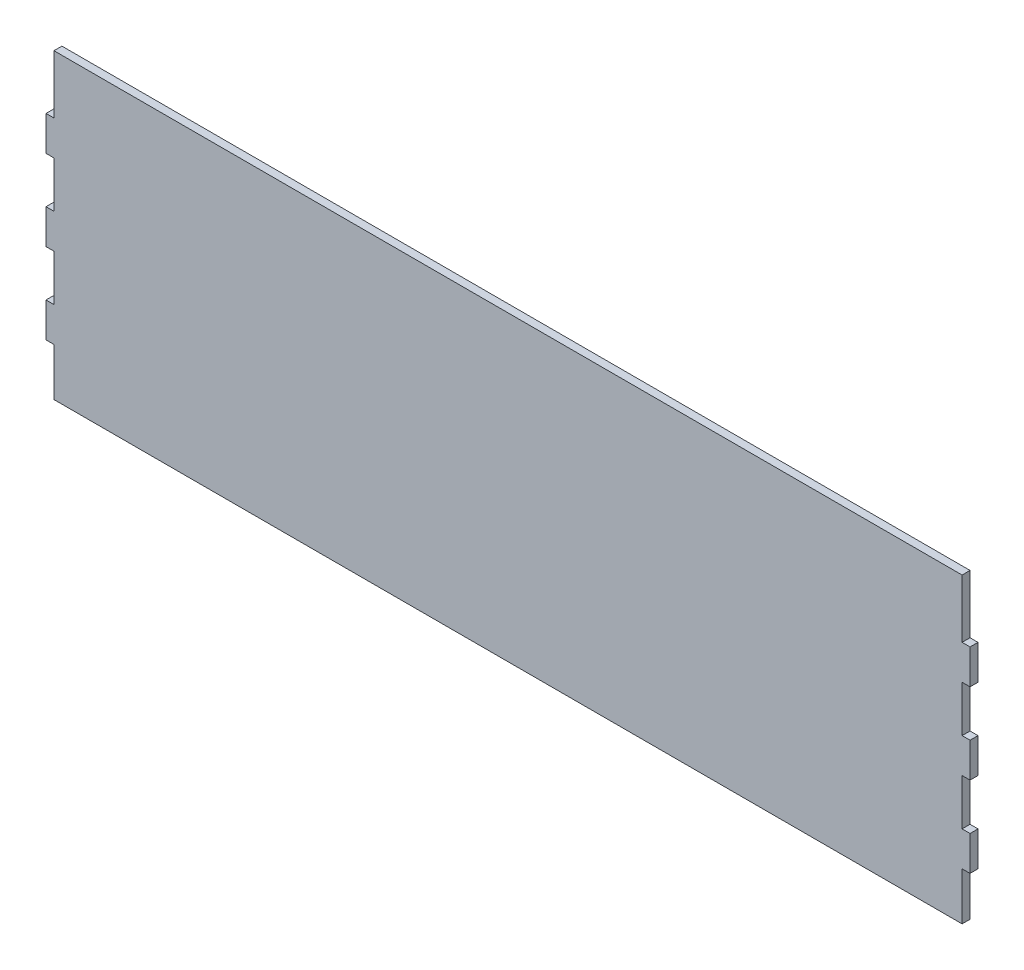
from build123d import *

# Parameters (mm, degrees)
CROQUIS1_W              = 348.64
CROQUIS1_H              = 110
SALIENTE_EXTRUIR1_DEPTH = 3
CROQUIS2_W              = 3
CROQUIS2_H              = 17.427708433
CORTAR_EXTRUIR1_DEPTH   = 3
CROQUIS4_W              = 342.64
CROQUIS4_H              = 4
SALIENTE_EXTRUIR3_DEPTH = 3
CROQUIS6_W              = 3.205128205
CROQUIS6_H              = 25
CORTAR_EXTRUIR4_DEPTH   = 1.5


with BuildPart() as part:
    # Croquis1 → Saliente-Extruir1 (new body)
    with BuildSketch(Plane.XY):
        Rectangle(CROQUIS1_W, CROQUIS1_H)
    extrude(amount=SALIENTE_EXTRUIR1_DEPTH)

    # Croquis2 → Cortar-Extruir1 (cut)
    with BuildSketch(Plane.XY.offset(3)):
        Polygon((-174.32, 55), (-174.32, 37), (-171.32, 37), (-171.32, 52), (-171.32, 55), align=None)
        with Locations((-172.82, 15.237951406)):
            Rectangle(CROQUIS2_W, CROQUIS2_H)
        Polygon((171.32, 55), (171.32, 52), (171.32, 37), (174.32, 37), (174.32, 55), align=None)
        with Locations((172.82, 15.237951406)):
            Rectangle(CROQUIS2_W, CROQUIS2_H)
        with Locations((172.82, -15.237951406)):
            Rectangle(CROQUIS2_W, CROQUIS2_H)
        Polygon((171.32, -37), (171.32, -52), (171.32, -55), (174.32, -55), (174.32, -37), align=None)
        with Locations((-172.82, -15.237951406)):
            Rectangle(CROQUIS2_W, CROQUIS2_H)
        Polygon((-171.32, -37), (-174.32, -37), (-174.32, -55), (-171.32, -55), (-171.32, -52), align=None)
    extrude(amount=-CORTAR_EXTRUIR1_DEPTH, mode=Mode.SUBTRACT)

    # Croquis4 → Saliente-Extruir3 (add)
    with BuildSketch(Plane(origin=(0, 0, 0), x_dir=(-1, 0, 0), z_dir=(0, 0, -1))):
        with Locations((0, 57)):
            Rectangle(CROQUIS4_W, CROQUIS4_H)
    extrude(amount=-SALIENTE_EXTRUIR3_DEPTH)

    # Croquis6 → Cortar-Extruir4 (cut)
    with BuildSketch(Plane(origin=(0, 0, 0), x_dir=(-1, 0, 0), z_dir=(0, 0, -1))):
        with Locations((-140.224358975, 1.792158121)):
            Rectangle(CROQUIS6_W, CROQUIS6_H)
        Polygon((-134.455128205, 11.728055557), (-134.455128205, 14.292158121), (-115.865384615, 14.292158121), (-115.865384615, 11.728055557), (-123.557692308, 11.728055557), (-123.557692308, -10.707841879), (-126.762820513, -10.707841879), (-126.762820513, 11.728055557), align=None)
        Polygon((-96.634615385, 14.292158121), (-80.608974359, -10.707841879), (-84.14463141, -10.707841879), (-89.282852564, -2.695021367), (-104.632411859, -2.695021367), (-109.765625, -10.707841879), (-113.301282051, -10.707841879), (-97.275641026, 14.292158121), align=None)
        Polygon((-96.955128205, 9.279137287), (-102.984775641, -0.130918802), (-90.925480769, -0.130918802), align=None, mode=Mode.SUBTRACT)
        Polygon((-76.762820513, -10.707841879), (-72.125400641, 14.292158121), (-71.359174679, 14.292158121), (-57.692307692, -6.220662392), (-44.060496795, 14.292158121), (-43.274238782, 14.292158121), (-38.621794872, -10.707841879), (-41.851963141, -10.707841879), (-45.192307692, 7.240876069), (-57.116386218, -10.707841879), (-58.23818109, -10.707841879), (-70.192307692, 7.240876069), (-73.522636218, -10.707841879), align=None)
        Polygon((-20.032051282, -10.707841879), (-15.39463141, 14.292158121), (-14.628405449, 14.292158121), (-0.961538462, -6.220662392), (12.670272436, 14.292158121), (13.456530449, 14.292158121), (18.108974359, -10.707841879), (14.87880609, -10.707841879), (11.538461538, 7.240876069), (-0.385616987, -10.707841879), (-1.507411859, -10.707841879), (-13.461538462, 7.240876069), (-16.791866987, -10.707841879), align=None)
        Polygon((38.942307692, 14.292158121), (54.967948718, -10.707841879), (51.432291667, -10.707841879), (46.294070513, -2.695021367), (30.944511218, -2.695021367), (25.811298077, -10.707841879), (22.275641026, -10.707841879), (38.301282051, 14.292158121), align=None)
        Polygon((38.621794872, 9.279137287), (32.592147436, -0.130918802), (44.651442308, -0.130918802), align=None, mode=Mode.SUBTRACT)
        Polygon((60.096153846, -10.707841879), (60.096153846, 14.292158121), (60.772235577, 14.292158121), (83.493589744, -5.043779379), (83.493589744, 14.292158121), (86.698717949, 14.292158121), (86.698717949, -10.707841879), (85.967548077, -10.707841879), (63.301282051, 8.578015492), (63.301282051, -10.707841879), align=None)
        Polygon((91.826923077, 11.728055557), (91.826923077, 14.292158121), (110.416666667, 14.292158121), (110.416666667, 11.728055557), (102.724358974, 11.728055557), (102.724358974, -10.707841879), (99.519230769, -10.707841879), (99.519230769, 11.728055557), align=None)
        with Locations((117.147435898, 1.792158121)):
            Rectangle(CROQUIS6_W, CROQUIS6_H)
        with BuildLine():
            Line((122.916666667, -5.885125533), (125.811298077, -4.61809829))
            add(Edge.make_bspline(
                [(125.811298077, -4.61809829), (126.079134183, -4.948828932), (126.598948573, -5.590708585), (127.455886705, -6.441989555), (128.344203555, -7.163717223), (129.265428947, -7.755696425), (130.218433099, -8.217148406), (131.202909583, -8.544278211), (132.219816035, -8.748410738), (132.910044148, -8.772575581), (133.258213141, -8.784764956)],
                knots=[0, 0, 0, 0, 1.153100415, 2.237928994, 3.267715421, 4.250694537, 5.200010397, 6.130235134, 7.056842024, 8, 8, 8, 8], degree=3))
            add(Edge.make_bspline(
                [(133.258213141, -8.784764956), (133.555740258, -8.778755132), (134.142883846, -8.766895273), (135.008675426, -8.650740895), (135.84791518, -8.474150934), (136.646235119, -8.218465611), (137.388944042, -7.912353035), (138.043426276, -7.537857204), (138.613214754, -7.125867537), (139.076303876, -6.654965879), (139.444975756, -6.156256427), (139.709295086, -5.635324075), (139.876613699, -5.097401137), (139.8947693, -4.731111717), (139.903846154, -4.54798611)],
                knots=[0, 0, 0, 0, 1.234946322, 2.437057917, 3.621386918, 4.792186349, 5.913673692, 6.950685597, 7.917097878, 8.823989919, 9.682310305, 10.482200698, 11.24117951, 12, 12, 12, 12], degree=3))
            add(Edge.make_bspline(
                [(139.903846154, -4.54798611), (139.888569667, -4.339109949), (139.857159466, -3.909636705), (139.615547043, -3.278288879), (139.222742246, -2.661518509), (138.875697849, -2.290530757), (138.691907051, -2.094059828)],
                knots=[0, 0, 0, 0, 0.891266884, 1.832546502, 2.852141077, 4, 4, 4, 4], degree=3))
            add(Edge.make_bspline(
                [(138.691907051, -2.094059828), (138.540102216, -1.950164991), (138.217751003, -1.644610327), (137.667469838, -1.202155446), (137.033235979, -0.735926222), (136.314404559, -0.246284059), (135.503971956, 0.257089099), (134.613477055, 0.788269018), (133.635427235, 1.340204303), (132.948614048, 1.703672691), (132.592147436, 1.892318377)],
                knots=[0, 0, 0, 0, 0.686583151, 1.457930583, 2.316350959, 3.271130926, 4.312923852, 5.448523807, 6.675744593, 8, 8, 8, 8], degree=3))
            add(Edge.make_bspline(
                [(132.592147436, 1.892318377), (132.237510468, 2.079587747), (131.560407637, 2.437138234), (130.607142889, 2.967867739), (129.75710731, 3.454887718), (129.010685897, 3.897858797), (128.370554522, 4.303750041), (127.830371709, 4.661960085), (127.397954032, 4.983902188), (127.155656218, 5.197915107), (127.048277244, 5.292759082)],
                knots=[0, 0, 0, 0, 1.477081008, 2.820167727, 4.018253159, 5.085363654, 6.016710654, 6.809673397, 7.472483683, 8, 8, 8, 8], degree=3))
            add(Edge.make_bspline(
                [(127.048277244, 5.292759082), (126.899172063, 5.439221896), (126.608962372, 5.724288635), (126.221177732, 6.176212436), (125.890907821, 6.638854451), (125.62779582, 7.114111096), (125.415541358, 7.59556052), (125.273043075, 8.089335583), (125.177317254, 8.591024354), (125.165935331, 8.929812923), (125.16025641, 9.098848826)],
                knots=[0, 0, 0, 0, 1.146298085, 2.231088214, 3.262770719, 4.259089116, 5.206734795, 6.142757943, 7.073343623, 8, 8, 8, 8], degree=3))
            add(Edge.make_bspline(
                [(125.16025641, 9.098848826), (125.173951718, 9.363930417), (125.20123989, 9.892110715), (125.415580641, 10.662668751), (125.762877319, 11.394518162), (126.242436963, 12.082518878), (126.84928073, 12.712062813), (127.564239472, 13.284955838), (128.402407213, 13.764868556), (129.328469973, 14.185233595), (130.335659749, 14.51364557), (131.393462518, 14.763216161), (132.498293552, 14.902437388), (133.247830564, 14.92282243), (133.62880609, 14.933183762)],
                knots=[0, 0, 0, 0, 0.837991933, 1.669715449, 2.51103144, 3.391796435, 4.311046708, 5.269785205, 6.280961058, 7.359168808, 8.483515025, 9.627901659, 10.794307153, 12, 12, 12, 12], degree=3))
            add(Edge.make_bspline(
                [(133.62880609, 14.933183762), (134.035066683, 14.923324113), (134.836244822, 14.903880103), (136.017698725, 14.727338561), (137.156325229, 14.441787488), (138.077682229, 14.111757565), (138.798246942, 13.777081534), (139.350181526, 13.48239656), (139.904821597, 13.134373958), (140.468575277, 12.742276902), (141.037540091, 12.299581913), (141.620000774, 11.814973261), (142.205053407, 11.276964153), (142.590968084, 10.896246688), (142.788461538, 10.701412928)],
                knots=[0, 0, 0, 0, 1.405653816, 2.772060901, 4.124540357, 5.464455874, 6.152189961, 6.873505445, 7.628766255, 8.417464194, 9.24967235, 10.123474671, 11.039680293, 12, 12, 12, 12], degree=3))
            Line((142.788461538, 10.701412928), (140.009014423, 9.163952992))
            add(Edge.make_bspline(
                [(140.009014423, 9.163952992), (139.841214888, 9.321748808), (139.517476041, 9.626187288), (139.033855267, 10.054457557), (138.570378262, 10.441976417), (138.118859517, 10.77938779), (137.692664915, 11.084654108), (137.282106573, 11.343670931), (136.893196788, 11.56726236), (136.396221944, 11.799492391), (135.773669465, 12.033896195), (134.997535294, 12.228502066), (134.188267582, 12.345503989), (133.63754111, 12.361150072), (133.358373397, 12.369081198)],
                knots=[0, 0, 0, 0, 1.090757227, 2.104418744, 3.058922886, 3.950667869, 4.773180918, 5.540787397, 6.24875931, 6.895899919, 8.136684285, 9.392563024, 10.678269059, 12, 12, 12, 12], degree=3))
            add(Edge.make_bspline(
                [(133.358373397, 12.369081198), (133.1797043, 12.365734157), (132.830259181, 12.359187939), (132.316177523, 12.321454476), (131.828171756, 12.245058411), (131.365124381, 12.144388368), (130.925735374, 12.022728389), (130.514923728, 11.857797905), (130.123285159, 11.676742652), (129.76439188, 11.460834232), (129.44081544, 11.226245833), (129.151926726, 10.982325505), (128.90877828, 10.720594755), (128.711742813, 10.441893689), (128.554860523, 10.151560212), (128.442995636, 9.846600473), (128.375713544, 9.529173313), (128.368841671, 9.312845724), (128.365384615, 9.204017095)],
                knots=[0, 0, 0, 0, 1.313325108, 2.568631369, 3.785020429, 4.940155346, 6.050776184, 7.130748553, 8.189961788, 9.218897277, 10.203040636, 11.125276616, 11.993537025, 12.820778982, 13.627662592, 14.411743185, 15.200990442, 16, 16, 16, 16], degree=3))
            add(Edge.make_bspline(
                [(128.365384615, 9.204017095), (128.371074242, 9.069924968), (128.382510232, 8.800403543), (128.479344576, 8.401805578), (128.623900379, 8.005901814), (128.840521607, 7.612083597), (129.139331549, 7.21540055), (129.530823694, 6.809252527), (130.021193177, 6.388698177), (130.391565592, 6.118070275), (130.588942308, 5.973848826)],
                knots=[0, 0, 0, 0, 0.78665982, 1.581164236, 2.397161757, 3.257217929, 4.210340804, 5.30621366, 6.564443029, 8, 8, 8, 8], degree=3))
            add(Edge.make_bspline(
                [(130.588942308, 5.973848826), (130.663736133, 5.924917813), (130.842517792, 5.807956718), (131.165579376, 5.618643174), (131.589152282, 5.385083357), (132.106200078, 5.094114929), (132.72382102, 4.758414504), (133.441398103, 4.378794299), (134.257533108, 3.947777037), (134.835642166, 3.644942404), (135.141225962, 3.484866454)],
                knots=[0, 0, 0, 0, 0.413296489, 0.987913535, 1.73101195, 2.650321429, 3.731633343, 4.981838745, 6.404624251, 8, 8, 8, 8], degree=3))
            add(Edge.make_bspline(
                [(135.141225962, 3.484866454), (135.507671917, 3.287789698), (136.214584792, 2.907607863), (137.223039189, 2.332357727), (138.141238961, 1.770658833), (138.971355163, 1.228519266), (139.711348867, 0.700406251), (140.364052795, 0.194013572), (140.923579204, -0.303932331), (141.399587984, -0.788382586), (141.805210145, -1.2644899), (142.153367852, -1.73549496), (142.444679742, -2.208810859), (142.68827498, -2.679399273), (142.874990805, -3.154685184), (143.010512296, -3.628935898), (143.095712874, -4.105880643), (143.104557277, -4.424111135), (143.108974359, -4.5830422)],
                knots=[0, 0, 0, 0, 1.683190155, 3.247051228, 4.695973564, 6.037077394, 7.257037481, 8.372933184, 9.37737009, 10.28471651, 11.118293945, 11.905760317, 12.651677107, 13.364453099, 14.046661357, 14.713624512, 15.35755677, 16, 16, 16, 16], degree=3))
            add(Edge.make_bspline(
                [(143.108974359, -4.5830422), (143.100533297, -4.807451983), (143.083747188, -5.253718937), (142.941780889, -5.908660245), (142.72070424, -6.542631638), (142.405214482, -7.152915412), (142.001447506, -7.741363765), (141.505914253, -8.304705414), (140.919043715, -8.839227755), (140.259470283, -9.351373637), (139.532910718, -9.817162786), (138.761362375, -10.228699097), (137.950779564, -10.576426882), (137.100458515, -10.855856798), (136.211467805, -11.076224088), (135.284452574, -11.235804283), (134.318683624, -11.333501319), (133.662425531, -11.343683688), (133.328325321, -11.34886752)],
                knots=[0, 0, 0, 0, 0.821223785, 1.633106332, 2.443421537, 3.274781478, 4.141460982, 5.051471945, 6.01646156, 7.045086945, 8.106874007, 9.173719902, 10.24479815, 11.333448576, 12.448700884, 13.596729641, 14.776497934, 16, 16, 16, 16], degree=3))
            add(Edge.make_bspline(
                [(133.328325321, -11.34886752), (133.069434581, -11.345296372), (132.557623196, -11.338236427), (131.799167129, -11.273591146), (131.057369671, -11.18356563), (130.336186884, -11.039564668), (129.631619778, -10.865546914), (128.94559643, -10.650535729), (128.277182179, -10.393317818), (127.624877772, -10.099132682), (126.988039404, -9.755863526), (126.368284196, -9.359285951), (125.758945536, -8.911395354), (125.164486176, -8.408359633), (124.576237502, -7.858033671), (124.00737681, -7.249954503), (123.447984821, -6.592220788), (123.096216022, -6.124075578), (122.916666667, -5.885125533)],
                knots=[0, 0, 0, 0, 1.013020015, 2.002679503, 2.977563883, 3.935999391, 4.878831289, 5.81696562, 6.747607914, 7.680334823, 8.615780759, 9.576373882, 10.557738869, 11.573283968, 12.622485734, 13.708629243, 14.830441634, 16, 16, 16, 16], degree=3))
        make_face()
    extrude(amount=-CORTAR_EXTRUIR4_DEPTH, mode=Mode.SUBTRACT)


solid = part.part
